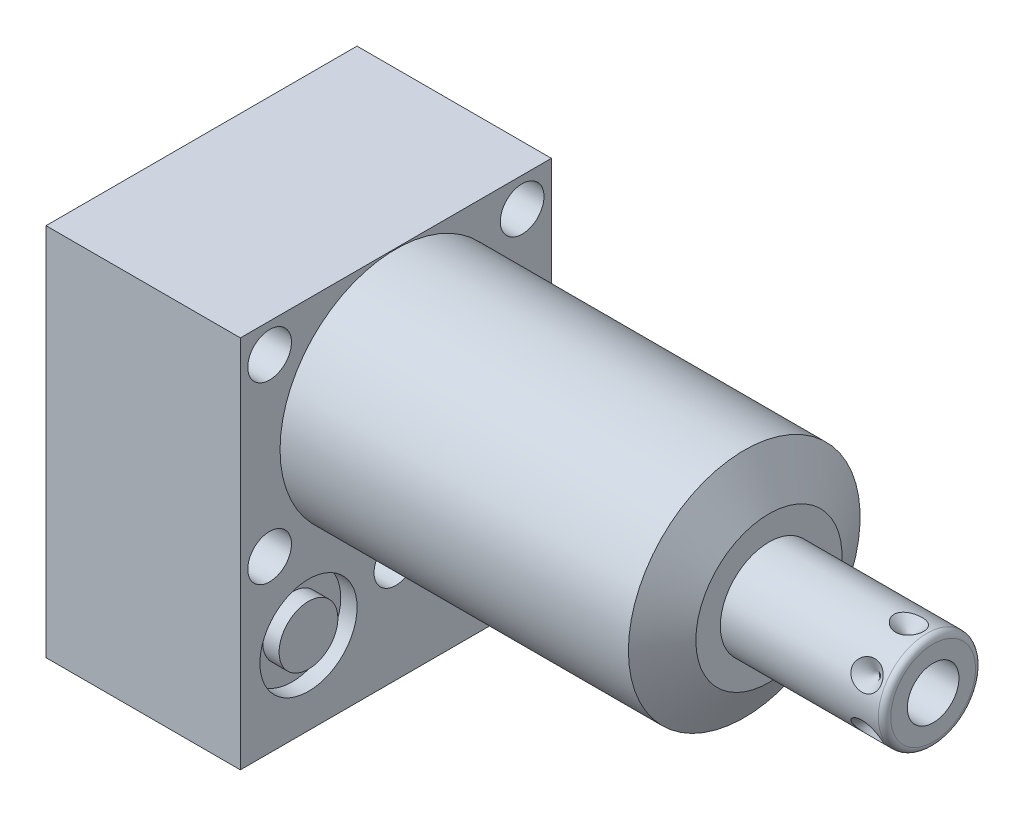
from build123d import *

# Parameters (mm, degrees)
SKETCH1_W           = 50.8
SKETCH1_H           = 61.1124
EXTRUDE1_DEPTH      = 60.9346
EXTRUDE1_DEPTH_BACK = 31.75
CUT_EXTRUDE1_REACH  = 62.935
SKETCH2_W           = 50.8
SKETCH2_H           = 61.1124
SKETCH2_R           = 18.923
SKETCH18_R          = 7.9375
CUT_EXTRUDE2_DEPTH  = 2.667
SKETCH19_R          = 7.9375
CUT_EXTRUDE3_DEPTH  = 2.667
SKETCH20_R          = 9.525
CUT_EXTRUDE4_DEPTH  = 0.254
SKETCH12_R          = 6.4389
EXTRUDE2_DEPTH      = 1.651
EXTRUDE3_START      = -2.667
SKETCH13_R          = 4.8006
EXTRUDE3_DEPTH      = 2.667
SKETCH14_R          = 1.7653
SKETCH15_R          = 1.7653
CIRPATTERN1_COUNT   = 6
SKETCH21_W          = 3.5687
SKETCH21_H          = 31.75
HOLE1_AT_2_COUNT    = 2
HOLE1_AT_2_PITCH    = 44.445239059
HOLE1_AT_3_COUNT    = 2
HOLE1_AT_3_PITCH    = 28.5496
HOLE1_AT_4_COUNT    = 2
HOLE1_AT_4_PITCH    = 41.2496
HOLE1_AT_5_COUNT    = 2
HOLE1_AT_5_PITCH    = 50.165816652
SKETCH24_R          = 4.8006
EXTRUDE4_DEPTH      = 2.667


with BuildPart() as part:
    # Sketch1 → Extrude1 (new body, two sides)
    with BuildSketch(Plane(origin=(0, 0, 0), x_dir=(0, 0, -1), z_dir=(1, 0, 0))) as extrude1_sk:
        with Locations((0, -11.5062)):
            Rectangle(SKETCH1_W, SKETCH1_H)
    extrude(amount=EXTRUDE1_DEPTH)
    extrude(extrude1_sk.sketch, amount=-EXTRUDE1_DEPTH_BACK)

    # Sketch2 → Cut-Extrude1 (cut, up to next)
    with BuildSketch(Plane(origin=(0, 0, 0), x_dir=(0, 0, -1), z_dir=(1, 0, 0)), mode=Mode.PRIVATE) as cut_extrude1_sk1:
        with Locations((0, -11.5062)):
            Rectangle(SKETCH2_W, SKETCH2_H)
        Circle(SKETCH2_R, mode=Mode.SUBTRACT)
    cut_extrude1_tool1 = extrude(cut_extrude1_sk1.sketch, amount=CUT_EXTRUDE1_REACH, mode=Mode.PRIVATE) & part.part
    add(cut_extrude1_tool1.solids().sort_by_distance((0, 18.970531, 0))[0], mode=Mode.SUBTRACT)

    # Sketch3 → Cut-Revolve1 (revolve, cut)
    with BuildSketch(Plane.XY, mode=Mode.PRIVATE) as cut_revolve1_sk:
        Polygon((56.90180837, 18.923), (60.9346, 11.938), (60.9346, 18.923), align=None)
    revolve(cut_revolve1_sk.sketch.rotate(Axis((56.700168788, 0, 0), (1, 0, 0)), 90), axis=Axis((56.700168788, 0, 0), (1, 0, 0)), mode=Mode.SUBTRACT)  # turned: the seam where the file's is

    # S2D0002 → Cut-Revolve2 (revolve, cut)
    with BuildSketch(Plane(origin=(-29.083, -28.575, 14.2748), x_dir=(0, 1, 0), z_dir=(0, 0, 1)), mode=Mode.PRIVATE) as cut_revolve2_sk:
        Polygon((0, 0), (4.5466, 0), (4.106586662, -2.0701), (3.4544, -2.722286662), (3.4544, -13.97), (0, -13.97), align=None)
    revolve(cut_revolve2_sk.sketch.rotate(Axis((-14.4145, -28.575, 14.2748), (-1, 0, 0)), 90), axis=Axis((-14.4145, -28.575, 14.2748), (-1, 0, 0)), mode=Mode.SUBTRACT)  # turned: the seam where the file's is

    # Sketch5 → Cut-Revolve3 (revolve, cut)
    with BuildSketch(Plane(origin=(-29.083, -28.575, -14.2748), x_dir=(0, 1, 0), z_dir=(0, 0, 1)), mode=Mode.PRIVATE) as cut_revolve3_sk:
        Polygon((0, 0), (4.5466, 0), (4.106586662, -2.0701), (3.4544, -2.722286662), (3.4544, -13.97), (0, -13.97), align=None)
    revolve(cut_revolve3_sk.sketch.rotate(Axis((-14.4145, -28.575, -14.2748), (-1, 0, 0)), 90), axis=Axis((-14.4145, -28.575, -14.2748), (-1, 0, 0)), mode=Mode.SUBTRACT)  # turned: the seam where the file's is

    # Sketch6 → Cut-Revolve4 (revolve, cut)
    with BuildSketch(Plane(origin=(-2.667, -28.575, 14.2748), x_dir=(0, -1, 0), z_dir=(0, 0, 1)), mode=Mode.PRIVATE) as cut_revolve4_sk:
        Polygon((0, 0), (4.5466, 0), (4.106586662, -2.0701), (3.4544, -2.722286662), (3.4544, -12.192), (0, -12.192), align=None)
    revolve(cut_revolve4_sk.sketch.rotate(Axis((-15.4686, -28.575, 14.2748), (1, 0, 0)), 90), axis=Axis((-15.4686, -28.575, 14.2748), (1, 0, 0)), mode=Mode.SUBTRACT)  # turned: the seam where the file's is

    # Sketch7 → Cut-Revolve5 (revolve, cut)
    with BuildSketch(Plane(origin=(-2.667, -28.575, -14.2748), x_dir=(0, -1, 0), z_dir=(0, 0, 1)), mode=Mode.PRIVATE) as cut_revolve5_sk:
        Polygon((0, 0), (4.5466, 0), (4.106586662, -2.0701), (3.4544, -2.722286662), (3.4544, -12.192), (0, -12.192), align=None)
    revolve(cut_revolve5_sk.sketch.rotate(Axis((-15.4686, -28.575, -14.2748), (1, 0, 0)), 90), axis=Axis((-15.4686, -28.575, -14.2748), (1, 0, 0)), mode=Mode.SUBTRACT)  # turned: the seam where the file's is

    # Sketch18 → Cut-Extrude2 (cut)
    with BuildSketch(Plane.ZY.offset(31.75)):
        with Locations((-14.2748, -28.575)):
            Circle(SKETCH18_R)
        with Locations((14.2748, -28.575)):
            Circle(SKETCH18_R)
    extrude(amount=-CUT_EXTRUDE2_DEPTH, mode=Mode.SUBTRACT)

    # Sketch19 → Cut-Extrude3 (cut)
    with BuildSketch(Plane(origin=(0, 0, 0), x_dir=(0, 0, -1), z_dir=(1, 0, 0))):
        with Locations((-14.2748, -28.575)):
            Circle(SKETCH19_R)
        with Locations((14.2748, -28.575)):
            Circle(SKETCH19_R)
    extrude(amount=-CUT_EXTRUDE3_DEPTH, mode=Mode.SUBTRACT)

    # Sketch8 → Cut-Revolve6 (revolve, cut)
    with BuildSketch(Plane(origin=(-15.875, -43.688, 14.2748), x_dir=(-1, 0, 0), z_dir=(0, 0, 1)), mode=Mode.PRIVATE) as cut_revolve6_sk:
        Polygon((0, -1.8796), (6.1849, -1.8796), (5.642306865, -4.4323), (4.9784, -5.096206865), (4.9784, -20.9296), (0, -20.9296), align=None)
    revolve(cut_revolve6_sk.sketch.rotate(Axis((-15.875, -17.018, 14.2748), (0, -1, 0)), 270), axis=Axis((-15.875, -17.018, 14.2748), (0, -1, 0)), mode=Mode.SUBTRACT)  # turned: the seam where the file's is

    # Sketch9 → Cut-Revolve7 (revolve, cut)
    with BuildSketch(Plane(origin=(-15.875, -43.688, -14.2748), x_dir=(-1, 0, 0), z_dir=(0, 0, 1)), mode=Mode.PRIVATE) as cut_revolve7_sk:
        Polygon((0, -1.8796), (6.1849, -1.8796), (5.642306865, -2.5527), (4.9784, -3.216606865), (4.9784, -20.9296), (0, -20.9296), align=None)
    revolve(cut_revolve7_sk.sketch.rotate(Axis((-15.875, -17.018, -14.2748), (0, -1, 0)), 270), axis=Axis((-15.875, -17.018, -14.2748), (0, -1, 0)), mode=Mode.SUBTRACT)  # turned: the seam where the file's is

    # Sketch20 → Cut-Extrude4 (cut)
    with BuildSketch(Plane.XZ.offset(42.0624)):
        with Locations(Location((-15.875, 14.2748, 0), (0, 0, 270))):  # turned: the seam where the file's is
            Circle(SKETCH20_R)
        with Locations(Location((-15.875, -14.2748, 0), (0, 0, 270))):  # turned: the seam where the file's is
            Circle(SKETCH20_R)
    extrude(amount=-CUT_EXTRUDE4_DEPTH, mode=Mode.SUBTRACT)

    # Sketch10 → Revolve1 (revolve)
    with BuildSketch(Plane.XY, mode=Mode.PRIVATE) as revolve1_sk:
        with BuildLine():
            Line((60.9346, 0), (60.9346, 7.9375))
            Line((60.9346, 7.9375), (86.741, 7.9375))
            ThreePointArc((86.741, 7.9375), (87.45942049, 7.63992049), (87.757, 6.9215))
            Line((87.757, 6.9215), (87.757, 0))
            Line((87.757, 0), (60.9346, 0))
        make_face()
    revolve(revolve1_sk.sketch.rotate(Axis((59.59348, 0, 0), (1, 0, 0)), 90), axis=Axis((59.59348, 0, 0), (1, 0, 0)))  # turned: the seam where the file's is

    # S2D0001 → Cut-Revolve8 (revolve, cut)
    with BuildSketch(Plane(origin=(87.757, -4.2164, 0), x_dir=(0, -1, 0), z_dir=(0, 0, 1)), mode=Mode.PRIVATE) as cut_revolve8_sk:
        Polygon((0, 0), (0, -15.24), (-4.2164, -17.773468714), (-4.2164, 0), align=None)
    revolve(cut_revolve8_sk.sketch.rotate(Axis((62.891960697, 0, 0), (1, 0, 0)), 270), axis=Axis((62.891960697, 0, 0), (1, 0, 0)), mode=Mode.SUBTRACT)  # turned: the seam where the file's is

    # Sketch12 → Extrude2 (add)
    with BuildSketch(Plane(origin=(-31.75, -41.8084, 0), x_dir=(0, 0, -1), z_dir=(0, -1, 0))):
        with Locations((-14.2748, 15.875)):
            Circle(SKETCH12_R)
    extrude(amount=EXTRUDE2_DEPTH)

    # Sketch13 → Extrude3 (add)
    with BuildSketch(Plane(origin=(0, 0, 0), x_dir=(0, 0, -1), z_dir=(1, 0, 0)).offset(EXTRUDE3_START)):
        with Locations((-14.2748, -28.575)):
            Circle(SKETCH13_R)
    extrude(amount=EXTRUDE3_DEPTH)

    # Sketch16 → Cut-Revolve9 (revolve, cut)
    with BuildSketch(Plane(origin=(83.7946, -7.9375, 0), x_dir=(-1, 0, 0), z_dir=(0, 0, 1)), mode=Mode.PRIVATE) as cut_revolve9_sk:
        Polygon((0, 0), (2.413, 0), (0, -2.413), align=None)
    cut_revolve9 = revolve(cut_revolve9_sk.sketch.rotate(Axis((83.7946, -4.132061843, 0), (0, -1, 0)), 90), axis=Axis((83.7946, -4.132061843, 0), (0, -1, 0)), mode=Mode.SUBTRACT)  # turned: the seam where the file's is

    # CirPattern1: Cut-Revolve9 ×6 about axis
    cirpattern1_axis = Axis((60.9356, 0, 0), (-1, 0, 0))
    for i in range(1, CIRPATTERN1_COUNT):
        add(cut_revolve9.rotate(cirpattern1_axis, i * 360 / CIRPATTERN1_COUNT), mode=Mode.SUBTRACT)

    # Sketch21 → Hole1 (revolve, cut)
    with BuildSketch(Plane(origin=(0, 14.2748, 20.6248), x_dir=(0, 0, -1), z_dir=(0, 1, 0))):
        with Locations((1.78435, 15.875)):
            Rectangle(SKETCH21_W, SKETCH21_H)
    hole1 = revolve(axis=Axis((-110, 14.2748, 20.6248), (1, 0, 0)), mode=Mode.SUBTRACT)

    # Hole1 at 2: Hole1 ×2
    with Locations(*[Vector(0, -0.885809163, -0.464049703) * (i * HOLE1_AT_2_PITCH) for i in range(1, HOLE1_AT_2_COUNT)]):
        add(hole1, mode=Mode.SUBTRACT)

    # Hole1 at 3: Hole1 ×2
    with Locations(*[(0, -i * HOLE1_AT_3_PITCH, 0) for i in range(1, HOLE1_AT_3_COUNT)]):
        add(hole1, mode=Mode.SUBTRACT)

    # Hole1 at 4: Hole1 ×2
    with Locations(*[(0, 0, -i * HOLE1_AT_4_PITCH) for i in range(1, HOLE1_AT_4_COUNT)]):
        add(hole1, mode=Mode.SUBTRACT)

    # Hole1 at 5: Hole1 ×2
    with Locations(*[Vector(0, -0.569104659, -0.822265095) * (i * HOLE1_AT_5_PITCH) for i in range(1, HOLE1_AT_5_COUNT)]):
        add(hole1, mode=Mode.SUBTRACT)

    # Sketch24 → Extrude4 (add)
    with BuildSketch(Plane.ZY.offset(29.083)):
        with Locations(Location((14.2748, -28.575, 0), (0, 0, 180))):  # turned: the seam where the file's is
            Circle(SKETCH24_R)
    extrude(amount=EXTRUDE4_DEPTH)


with BuildPart() as body_2:
    # Sketch14 → Revolve2 (revolve)
    with BuildSketch(Plane(origin=(0, -28.575, -14.2748), x_dir=(0, 0, -1), z_dir=(0, -1, 0)), mode=Mode.PRIVATE) as revolve2_sk:
        with Locations((6.1722, -0.9017)):
            Circle(SKETCH14_R)
    revolve(revolve2_sk.sketch.rotate(Axis((-2.84353, -28.575, -14.2748), (1, 0, 0)), 180), axis=Axis((-2.84353, -28.575, -14.2748), (1, 0, 0)))  # turned: the seam where the file's is


with BuildPart() as body_3:
    # Sketch15 → Revolve3 (revolve)
    with BuildSketch(Plane(origin=(0, -28.575, -14.2748), x_dir=(0, 0, -1), z_dir=(0, -1, 0)), mode=Mode.PRIVATE) as revolve3_sk:
        with Locations((6.1722, -30.8483)):
            Circle(SKETCH15_R)
    revolve(revolve3_sk.sketch.rotate(Axis((-32.79013, -28.575, -14.2748), (1, 0, 0)), 180), axis=Axis((-32.79013, -28.575, -14.2748), (1, 0, 0)))  # turned: the seam where the file's is


solid = Compound([part.part, body_2.part, body_3.part])
